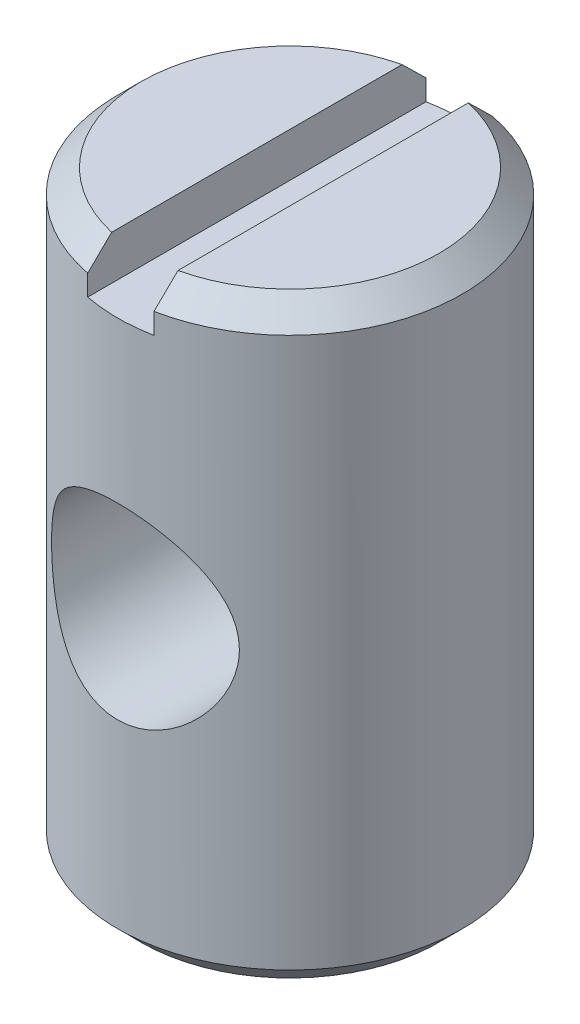
from build123d import *

# Parameters (mm, degrees)
SKETCH4_W               = 1.524
SKETCH4_H               = 9.039794808
CUT_EXTRUDE2_DEPTH      = 1.016
SKETCH9_R               = 2.159
CUT_EXTRUDE3_DEPTH      = 4.9624
CUT_EXTRUDE3_DEPTH_BACK = 4.9624


with BuildPart() as part:
    # Sketch3 → Revolve1 (revolve)
    with BuildSketch(Plane.XY):
        Polygon((3.423584633, 13.716), (3.9624, 13.177184633), (3.9624, 0.538815367), (3.423584633, 0), (0, 0), (0, 13.716), align=None)
    revolve(axis=Axis((0, 0, 0), (0, 1, 0)))

    # Sketch4 → Cut-Extrude2 (cut)
    with BuildSketch(Plane(origin=(0, 13.716, 0), x_dir=(1, 0, 0), z_dir=(0, 1, 0))):
        with Locations((0, -0.098453211)):
            Rectangle(SKETCH4_W, SKETCH4_H)
    extrude(amount=-CUT_EXTRUDE2_DEPTH, mode=Mode.SUBTRACT)

    # Sketch9 → Cut-Extrude3 (cut, two sides)
    with BuildSketch(Plane.XY) as cut_extrude3_sk:
        with Locations((0, 6.858)):
            Circle(SKETCH9_R)
    extrude(amount=CUT_EXTRUDE3_DEPTH, mode=Mode.SUBTRACT)
    extrude(cut_extrude3_sk.sketch, amount=-CUT_EXTRUDE3_DEPTH_BACK, mode=Mode.SUBTRACT)


solid = part.part
